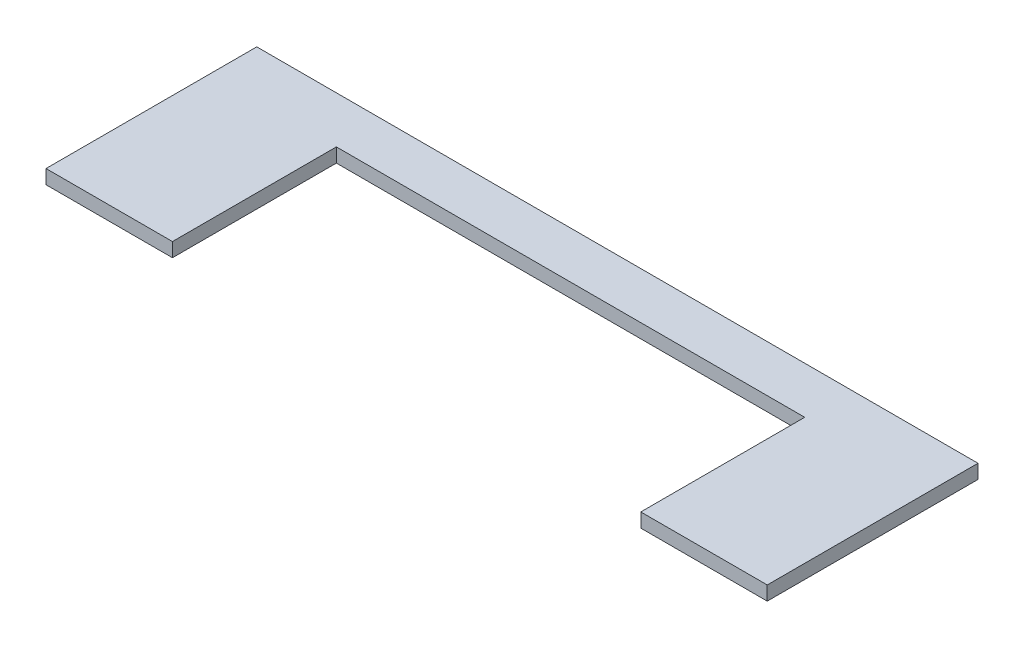
from build123d import *

# Parameters (mm, degrees)
BOSS_EXTRUDE1_DEPTH = 6


with BuildPart() as part:
    # Sketch1 → Boss-Extrude1 (new body)
    with BuildSketch(Plane(origin=(0, 0, 0), x_dir=(1, 0, 0), z_dir=(0, 1, 0))):
        Polygon((-39.389366712, -45), (-39.389366712, 25), (160.610633288, 25), (160.610633288, -45), (214.610633288, -45), (214.610633288, 45), (40.228314039, 45), (-93.389366712, 45), (-93.389366712, -45), align=None)
    extrude(amount=BOSS_EXTRUDE1_DEPTH)


solid = part.part
